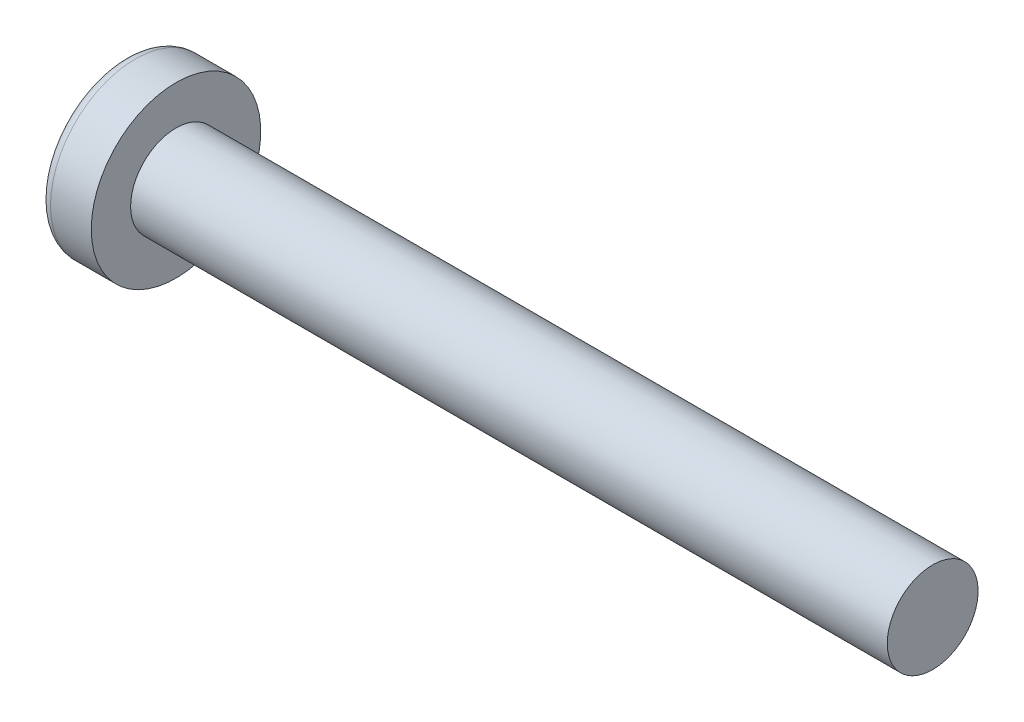
from build123d import *

# Parameters (mm, degrees)
SKETCH3_W         = 0.74
SKETCH3_H         = 2.9
SKETCH4_W         = 0.37
SKETCH4_H         = 0.37
CIRPATTERN1_COUNT = 2
CIRPATTERN1_ANGLE = 90


with BuildPart() as part:
    # BodySke → Base-Revolve (revolve)
    with BuildSketch(Plane.XY):
        with BuildLine():
            Line((2.4, 1.5), (2.4, 2.8))
            Line((2.4, 2.8), (1.053355856, 2.8))
            ThreePointArc((1.053355856, 2.8), (0.878072834, 2.754445324), (0.747150707, 2.629310345))
            ThreePointArc((0.747150707, 2.629310345), (0.190413403, 1.366702882), (0, 0))
            Line((0, 0), (27.4, 0))
            Line((27.4, 0), (27.4, 1.5))
            Line((27.4, 1.5), (2.4, 1.5))
        make_face()
    revolve(axis=Axis((-25.4, 0, 0), (1, 0, 0)))

    # Sketch3 → Cut-Loft1 section 0
    with BuildSketch(Plane(origin=(0, 0, 0), x_dir=(0, 0, -1), z_dir=(1, 0, 0))):
        Rectangle(SKETCH3_W, SKETCH3_H)
    # Sketch4 → Cut-Loft1 section 1
    with BuildSketch(Plane(origin=(1.76, 0, 0), x_dir=(0, 0, -1), z_dir=(1, 0, 0))):
        Rectangle(SKETCH4_W, SKETCH4_H)
    cut_loft1 = loft(mode=Mode.SUBTRACT)

    # CirPattern1: Cut-Loft1 ×2 about axis
    cirpattern1_axis = Axis((-25.4, 0, 0), (1, 0, 0))
    for i in range(1, CIRPATTERN1_COUNT):
        add(cut_loft1.rotate(cirpattern1_axis, i * CIRPATTERN1_ANGLE / (CIRPATTERN1_COUNT - 1)), mode=Mode.SUBTRACT)


solid = part.part
